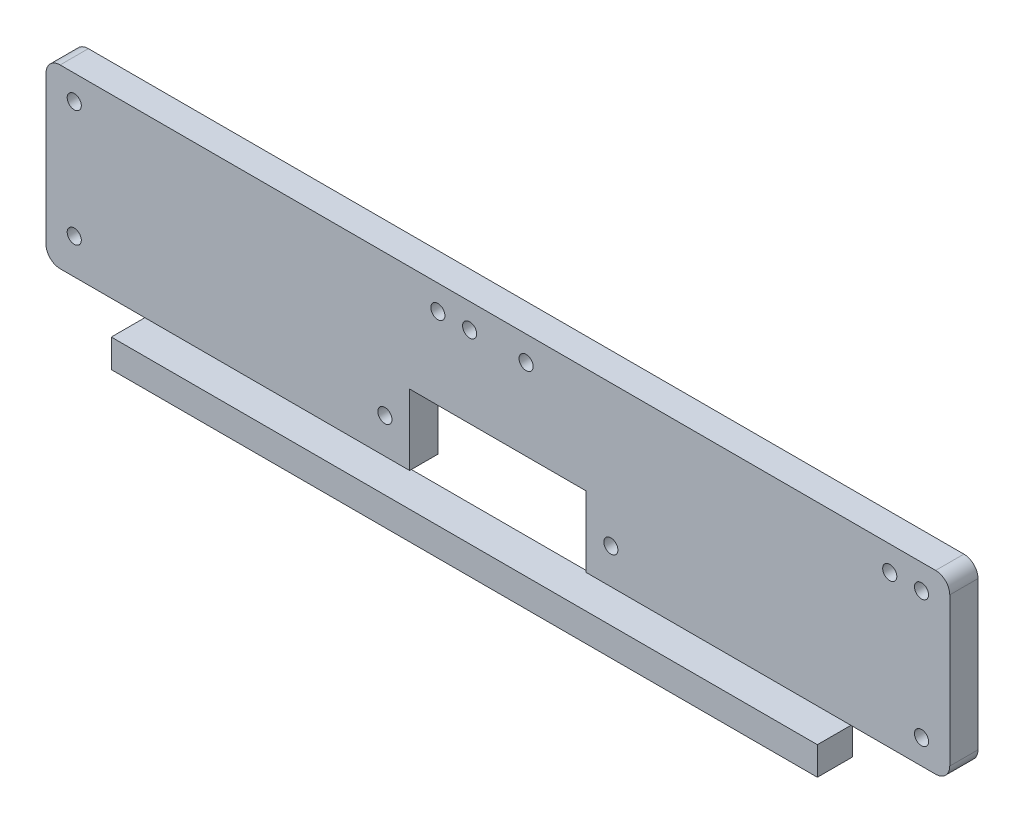
from build123d import *

# Parameters (mm, degrees)
SKETCH1_W            = 256
SKETCH1_H            = 50
SKETCH1_R            = 2
BOSS_EXTRUDE1_DEPTH  = 8
FILLET1_R            = 4
SKETCH2_W            = 7
SKETCH2_H            = 8
BOSS_EXTRUDE2_DEPTH  = 8
SKETCH3_W            = 50
SKETCH3_H            = 20
CUT_EXTRUDE1_DEPTH   = 8
SKETCH4_R            = 2
CUT_EXTRUDE2_DEPTH   = 8
SKETCH5_R            = 1.75
CUT_EXTRUDE3_DEPTH   = 113
BOSS_EXTRUDE12_START = 7.5
SKETCH8_W            = 200
SKETCH8_H            = 8
BOSS_EXTRUDE12_DEPTH = 10


with BuildPart() as part:
    # Sketch1 → Boss-Extrude1 (new body)
    with BuildSketch(Plane.XY):
        with Locations((0.283809042, 47.106089777)):
            Rectangle(SKETCH1_W, SKETCH1_H)
        with Locations((120.283809042, 65.106089777)):
            Circle(SKETCH1_R, mode=Mode.SUBTRACT)
        with Locations((111.283809042, 65.106089777)):
            Circle(SKETCH1_R, mode=Mode.SUBTRACT)
        with Locations((8.283809042, 65.106089777)):
            Circle(SKETCH1_R, mode=Mode.SUBTRACT)
        with Locations((-7.716190958, 65.106089777)):
            Circle(SKETCH1_R, mode=Mode.SUBTRACT)
        with Locations((-16.716190958, 65.106089777)):
            Circle(SKETCH1_R, mode=Mode.SUBTRACT)
        with Locations((-119.716190958, 65.106089777)):
            Circle(SKETCH1_R, mode=Mode.SUBTRACT)
    extrude(amount=BOSS_EXTRUDE1_DEPTH)

    # Fillet1
    fillet1_edges = [part.edges().sort_by_distance(p)[0] for p in [
        (-127.716190958, 72.106089777, 4),
        (128.283809042, 72.106089777, 4),
        (128.283809042, 22.106089777, 4),
        (-127.716190958, 22.106089777, 4),
    ]]
    fillet(fillet1_edges, radius=FILLET1_R)

    # Sketch2 → Boss-Extrude2 (add)
    with BuildSketch(Plane.XY.offset(8)):
        with Locations((36.783809042, 18.106089777)):
            Rectangle(SKETCH2_W, SKETCH2_H)
        with Locations((-36.216190958, 18.106089777)):
            Rectangle(SKETCH2_W, SKETCH2_H)
    extrude(amount=-BOSS_EXTRUDE2_DEPTH)

    # Sketch3 → Cut-Extrude1 (cut)
    with BuildSketch(Plane.XY.offset(8)):
        with Locations((0.283809042, 32.106089777)):
            Rectangle(SKETCH3_W, SKETCH3_H)
    extrude(amount=-CUT_EXTRUDE1_DEPTH, mode=Mode.SUBTRACT)

    # Sketch4 → Cut-Extrude2 (cut)
    with BuildSketch(Plane.XY.offset(8)):
        with Locations((-31.716190958, 32.106089777)):
            Circle(SKETCH4_R)
        with Locations((32.283809042, 32.106089777)):
            Circle(SKETCH4_R)
        with Locations((-119.716190958, 32.106089777)):
            Circle(SKETCH4_R)
        with Locations((120.283809042, 29.106089777)):
            Circle(SKETCH4_R)
    extrude(amount=-CUT_EXTRUDE2_DEPTH, mode=Mode.SUBTRACT)

    # Sketch5 → Cut-Extrude3 (cut)
    with BuildSketch(Plane.ZY.offset(39.716190958)):
        with Locations((3.5, 18.106089777)):
            Circle(SKETCH5_R)
    extrude(amount=-CUT_EXTRUDE3_DEPTH, mode=Mode.SUBTRACT)

    # Sketch8 → Boss-Extrude12 (add)
    with BuildSketch(Plane.XY.offset(BOSS_EXTRUDE12_START)):
        with Locations((0.283809042, 18.106089777)):
            Rectangle(SKETCH8_W, SKETCH8_H)
    extrude(amount=BOSS_EXTRUDE12_DEPTH)


solid = part.part
